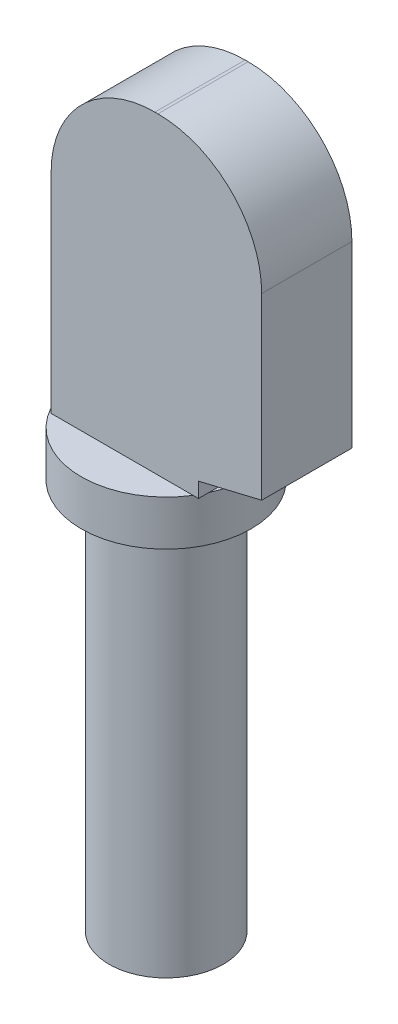
from build123d import *

# Parameters (mm, degrees)
BOSS_EXTRUDE1_DEPTH = 1.5


with BuildPart() as part:
    # Sketch1 → Revolve1 (revolve)
    with BuildSketch(Plane.XY):
        Polygon((0, 0), (1.9, 0), (1.9, 13), (2.825, 13), (2.825, 14.5), (0, 14.5), align=None)
    revolve(axis=Axis((0, 0, 0), (0, 1, 0)))

    # Sketch2 → Boss-Extrude1 (add, symmetric)
    with BuildSketch(Plane.XY):
        with BuildLine():
            Line((-2.325, 14.5), (-2.325, 21.45))
            ThreePointArc((-2.325, 21.45), (-1.314518395, 23.889518395), (1.125, 24.9))
            Line((1.125, 24.9), (1.225, 24.9))
            ThreePointArc((1.225, 24.9), (3.664518395, 23.889518395), (4.675, 21.45))
            Line((4.675, 21.45), (4.675, 15.5))
            Line((4.675, 15.5), (2.575, 15))
            Line((2.575, 15), (2.575, 14.5))
            Line((2.575, 14.5), (-2.325, 14.5))
        make_face()
    extrude(amount=BOSS_EXTRUDE1_DEPTH, both=True)


solid = part.part
